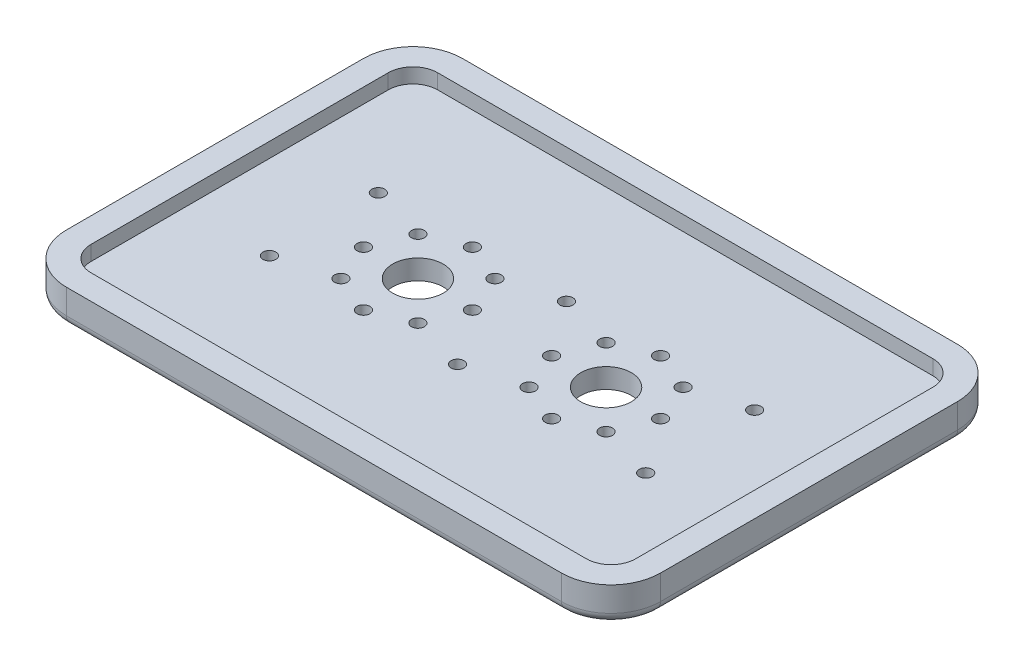
from build123d import *

# Parameters (mm, degrees)
SKETCH1_W                                        = 120
SKETCH1_H                                        = 80
BOSS_EXTRUDE1_DEPTH                              = 7
SKETCH2_W                                        = 110
SKETCH2_H                                        = 70
CUT_EXTRUDE1_DEPTH                               = 3
F_2_6_2_6_DIAMETER_HOLE1_D                       = 2.6
F_2_6_2_6_DIAMETER_HOLE1_DEPTH                   = 4
F_10_2_10_2_DIAMETER_HOLE1_D                     = 10.2
F_10_2_10_2_DIAMETER_HOLE1_DEPTH                 = 4
CBORE_FOR_M2_HEX_HEAD_MACHINE_SCREW1_D           = 2.6
CBORE_FOR_M2_HEX_HEAD_MACHINE_SCREW1_DEPTH       = 7
CBORE_FOR_M2_HEX_HEAD_MACHINE_SCREW1_CBORE_D     = 5
CBORE_FOR_M2_HEX_HEAD_MACHINE_SCREW1_CBORE_DEPTH = 1.5
FILLET1_R                                        = 10
FILLET2_R                                        = 2
FILLET3_R                                        = 5


with BuildPart() as part:
    # Sketch1 → Boss-Extrude1 (new body)
    with BuildSketch(Plane(origin=(0, 7, 0), x_dir=(1, 0, 0), z_dir=(0, 1, 0))):
        Rectangle(SKETCH1_W, SKETCH1_H)
    extrude(amount=-BOSS_EXTRUDE1_DEPTH)

    # Sketch2 → Cut-Extrude1 (cut)
    with BuildSketch(Plane(origin=(0, 7, 0), x_dir=(-1, 0, 0), z_dir=(0, 1, 0))):
        Rectangle(SKETCH2_W, SKETCH2_H)
    extrude(amount=-CUT_EXTRUDE1_DEPTH, mode=Mode.SUBTRACT)

    # Ø2.6 (2.6) Diameter Hole1
    with Locations(Plane(origin=(0, 4, 0), x_dir=(1, 0, 0), z_dir=(0, 1, 0))):
        with Locations((-38, -11), (0, 11), (-11.221825407, -7.778174593), (-19, -11), (-26.778174593, -7.778174593), (-26.778174593, 7.778174593), (-19, 11), (-11.221825407, 7.778174593), (11.221825407, 7.778174593), (19, 11), (26.778174593, 7.778174593), (30, 0), (26.778174593, -7.778174593), (19, -11), (11.221825407, -7.778174593), (-8, 0)):
            Hole(F_2_6_2_6_DIAMETER_HOLE1_D / 2, depth=F_2_6_2_6_DIAMETER_HOLE1_DEPTH)

    # Ø10.2 (10.2) Diameter Hole1
    with Locations(Plane(origin=(0, 4, 0), x_dir=(1, 0, 0), z_dir=(0, 1, 0))):
        with Locations((19, 0), (-19, 0)):
            Hole(F_10_2_10_2_DIAMETER_HOLE1_D / 2, depth=F_10_2_10_2_DIAMETER_HOLE1_DEPTH)

    # CBORE for M2 Hex Head Machine Screw1
    with Locations(Plane(origin=(0, 0, 0), x_dir=(-1, 0, 0), z_dir=(0, -1, 0))):
        with Locations((-8, 0), (30, 0), (38, 11), (-38, 11), (0, -11), (-38, -11)):
            CounterBoreHole(CBORE_FOR_M2_HEX_HEAD_MACHINE_SCREW1_D / 2, CBORE_FOR_M2_HEX_HEAD_MACHINE_SCREW1_CBORE_D / 2, CBORE_FOR_M2_HEX_HEAD_MACHINE_SCREW1_CBORE_DEPTH, depth=CBORE_FOR_M2_HEX_HEAD_MACHINE_SCREW1_DEPTH)

    # Fillet1
    fillet1_edges = [part.edges().sort_by_distance(p)[0] for p in [
        (-60, 3.5, -40),
        (60, 3.5, -40),
        (60, 3.5, 40),
        (-60, 3.5, 40),
    ]]
    fillet(fillet1_edges, radius=FILLET1_R)

    # Fillet2
    fillet2_edges = [part.edges().sort_by_distance(p)[0] for p in [
        (-60, 0, 0),
        (0, 0, 40),
        (0, 0, -40),
        (60, 0, 0),
        (57.071067812, 0, 37.071067812),
        (57.071067812, 0, -37.071067812),
        (-57.071067812, 0, -37.071067812),
        (-57.071067812, 0, 37.071067812),
    ]]
    fillet(fillet2_edges, radius=FILLET2_R)

    # Fillet3
    fillet3_edges = [part.edges().sort_by_distance(p)[0] for p in [
        (-55, 5.5, 35),
        (-55, 5.5, -35),
        (55, 5.5, -35),
        (55, 5.5, 35),
    ]]
    fillet(fillet3_edges, radius=FILLET3_R)


solid = part.part
